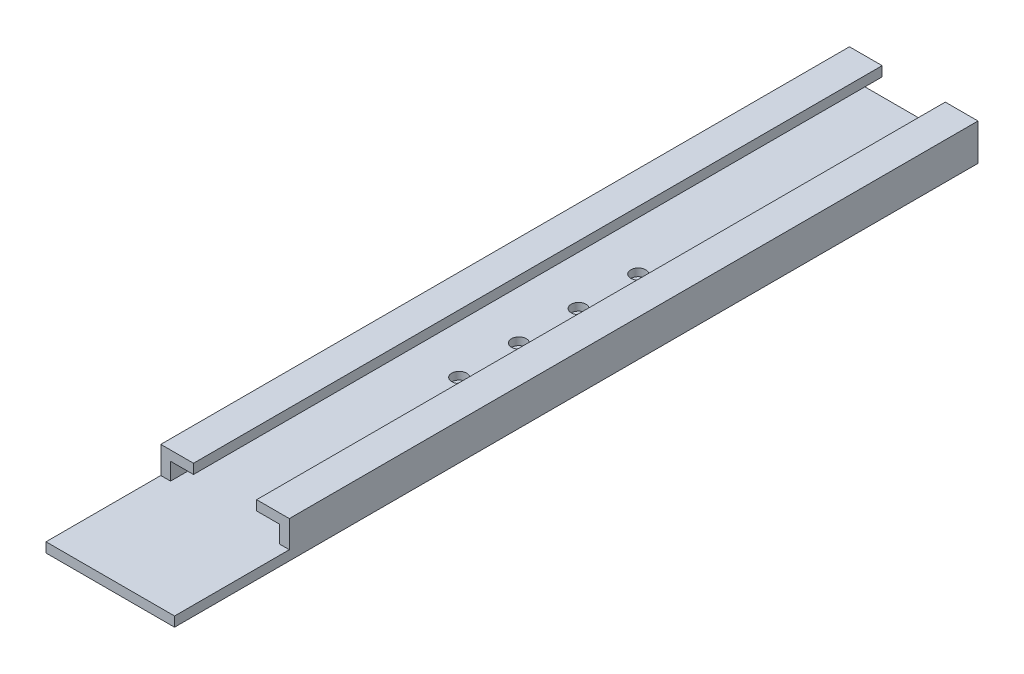
from build123d import *

# Parameters (mm, degrees)
BOSS_EXTRUDE1_DEPTH = 600
SKETCH4_W           = 112
SKETCH4_H           = 100
BOSS_EXTRUDE2_DEPTH = 8.5
SKETCH6_R           = 3.3
CUT_EXTRUDE1_DEPTH  = 9.5
SKETCH7_R           = 6.5
CUT_EXTRUDE2_DEPTH  = 6.6


with BuildPart() as part:
    # Sketch1 → Boss-Extrude1 (new body)
    with BuildSketch(Plane.XY):
        Polygon((0, 0), (95, 0), (95, 15), (75, 15), (75, 23.5), (103.5, 23.5), (103.5, -8.5), (-8.5, -8.5), (-8.5, 23.5), (20, 23.5), (20, 15), (0, 15), align=None)
    extrude(amount=BOSS_EXTRUDE1_DEPTH)

    # Sketch4 → Boss-Extrude2 (add)
    with BuildSketch(Plane.XZ.offset(8.5)):
        with Locations((47.5, 650)):
            Rectangle(SKETCH4_W, SKETCH4_H)
    extrude(amount=-BOSS_EXTRUDE2_DEPTH)

    # Sketch6 → Cut-Extrude1 (cut, through all)
    with BuildSketch(Plane(origin=(0, 0, 0), x_dir=(1, 0, 0), z_dir=(0, 1, 0))):
        with Locations((47.5, -240)):
            Circle(SKETCH6_R)
        with Locations((47.5, -292)):
            Circle(SKETCH6_R)
        with Locations((47.5, -344)):
            Circle(SKETCH6_R)
        with Locations((47.5, -396)):
            Circle(SKETCH6_R)
    extrude(amount=-CUT_EXTRUDE1_DEPTH, mode=Mode.SUBTRACT)

    # Sketch7 → Cut-Extrude2 (cut)
    with BuildSketch(Plane(origin=(0, 0, 0), x_dir=(1, 0, 0), z_dir=(0, 1, 0))):
        with Locations((47.5, -240)):
            Circle(SKETCH7_R)
        with Locations((47.5, -292)):
            Circle(SKETCH7_R)
        with Locations((47.5, -344)):
            Circle(SKETCH7_R)
        with Locations((47.5, -396)):
            Circle(SKETCH7_R)
    extrude(amount=-CUT_EXTRUDE2_DEPTH, mode=Mode.SUBTRACT)


solid = part.part
